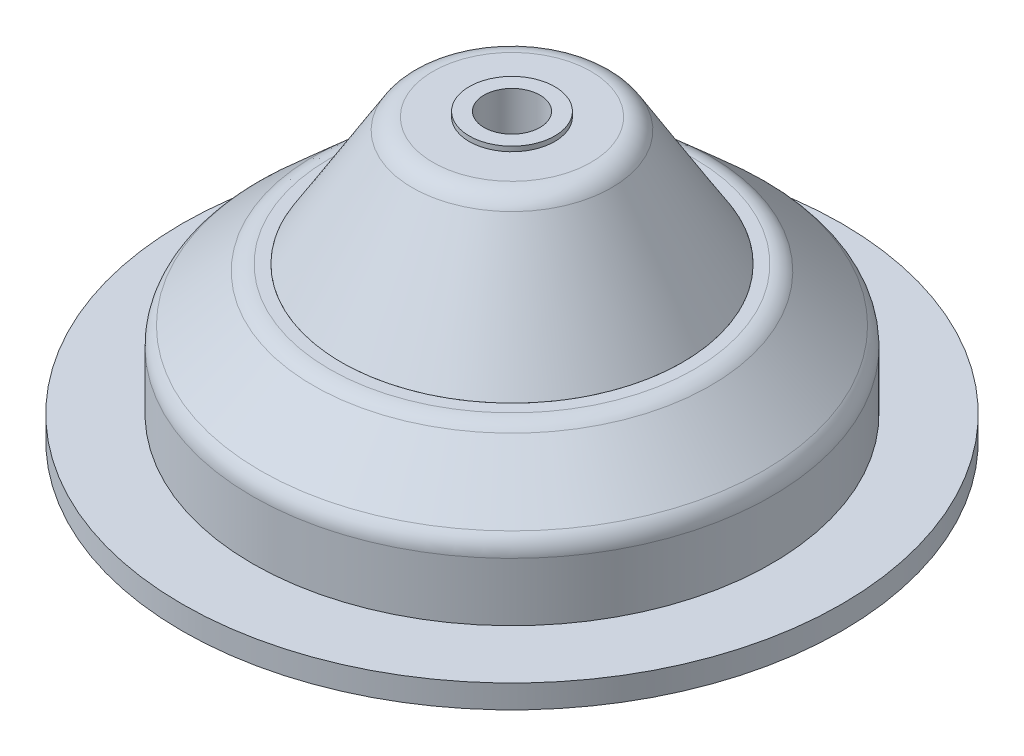
from build123d import *

# Parameters (mm, degrees)
SKETCH2_R           = 4.47675
SKETCH2_R_2         = 2.9337
BOSS_EXTRUDE1_DEPTH = 0.508
SKETCH3_R           = 6.99135
SKETCH3_R_2         = 2.9337
BOSS_EXTRUDE2_DEPTH = 8.0899
SKETCH4_R           = 6.0452
SKETCH4_R_2         = 2.9337
BOSS_EXTRUDE3_DEPTH = 1.016
BOSS_EXTRUDE4_DEPTH = 7.62


with BuildPart() as part:
    # Sketch1 → Revolve1 (revolve)
    with BuildSketch(Plane.XY):
        with BuildLine():
            Line((27.17165, 0), (34.5186, 0))
            Line((34.5186, 0), (34.5186, 2.4384))
            Line((34.5186, 2.4384), (27.17165, 2.4384))
            Line((27.17165, 2.4384), (27.17165, 8.540823407))
            ThreePointArc((27.17165, 8.540823407), (26.950119612, 9.578271554), (26.324170742, 10.434754118))
            Line((26.324170742, 10.434754118), (20.788951535, 15.381330711))
            ThreePointArc((20.788951535, 15.381330711), (20.002249757, 15.860392204), (19.096430792, 16.0274))
            Line((19.096430792, 16.0274), (17.84985, 16.0274))
            Line((17.84985, 16.0274), (24.9555, 9.6774))
            Line((24.9555, 9.6774), (24.9555, 0))
            Line((24.9555, 0), (27.17165, 0))
        make_face()
    revolve(axis=Axis((0, 0, 0), (0, 1, 0)))


with BuildPart() as body_2:
    # Sketch1_3 → Revolve2 (revolve)
    with BuildSketch(Plane.XY):
        with BuildLine():
            Line((2.9337, 16.0274), (17.84985, 16.0274))
            Line((17.84985, 16.0274), (10.433708778, 28.148063183))
            ThreePointArc((10.433708778, 28.148063183), (9.508951147, 29.038114838), (8.26709457, 29.3624))
            Line((8.26709457, 29.3624), (2.9337, 29.3624))
            Line((2.9337, 29.3624), (2.9337, 16.0274))
        make_face()
    revolve(axis=Axis((0, 0, 0), (0, 1, 0)))

    # Sketch2 → Boss-Extrude1 (add)
    with BuildSketch(Plane(origin=(0, 29.3624, 0), x_dir=(1, 0, 0), z_dir=(0, 1, 0))):
        Circle(SKETCH2_R)
        Circle(SKETCH2_R_2, mode=Mode.SUBTRACT)
    extrude(amount=BOSS_EXTRUDE1_DEPTH)

    # Sketch3 → Boss-Extrude2 (add)
    with BuildSketch(Plane.XZ.offset(-16.0274)):
        Circle(SKETCH3_R)
        Circle(SKETCH3_R_2, mode=Mode.SUBTRACT)
    extrude(amount=BOSS_EXTRUDE2_DEPTH)

    # Sketch4 → Boss-Extrude3 (add)
    with BuildSketch(Plane.XZ.offset(-7.9375)):
        Circle(SKETCH4_R)
        Circle(SKETCH4_R_2, mode=Mode.SUBTRACT)
    extrude(amount=BOSS_EXTRUDE3_DEPTH)

    # Sketch5 → Boss-Extrude4 (add)
    with BuildSketch(Plane.XZ.offset(-16.0274)):
        with BuildLine():
            ThreePointArc((-6.379230805, 2.860837142), (-6.034045723, 3.531184933), (-5.618677723, 4.160460968))
            Line((-5.618677723, 4.160460968), (-14.765958792, 10.029137848))
            ThreePointArc((-14.765958792, 10.029137848), (-15.510246483, 8.834557095), (-16.158099934, 7.585047892))
            Line((-16.158099934, 7.585047892), (-6.379230805, 2.860837142))
        make_face()
        with BuildLine():
            ThreePointArc((-5.667173044, -4.094157363), (-6.075118719, -3.460044417), (-6.412403751, -2.78568716))
            Line((-6.412403751, -2.78568716), (-16.068467551, -7.773126501))
            ThreePointArc((-16.068467551, -7.773126501), (-15.406074117, -9.014988925), (-14.647894131, -10.200801074))
            Line((-14.647894131, -10.200801074), (-5.667173044, -4.094157363))
        make_face()
        with BuildLine():
            Line((16.158099934, -7.585047892), (6.379230805, -2.860837142))
            ThreePointArc((6.379230805, -2.860837142), (6.034045723, -3.531184933), (5.618677723, -4.160460968))
            Line((5.618677723, -4.160460968), (14.765958792, -10.029137848))
            ThreePointArc((14.765958792, -10.029137848), (15.510246483, -8.834557095), (16.158099934, -7.585047892))
        make_face()
        with BuildLine():
            Line((14.647894131, 10.200801074), (5.667173044, 4.094157363))
            ThreePointArc((5.667173044, 4.094157363), (6.075118719, 3.460044417), (6.412403751, 2.78568716))
            Line((6.412403751, 2.78568716), (16.068467551, 7.773126501))
            ThreePointArc((16.068467551, 7.773126501), (15.406074117, 9.014988925), (14.647894131, 10.200801074))
        make_face()
        with BuildLine():
            ThreePointArc((0.712057762, -6.954994505), (-0.041072996, -6.991229351), (-0.793726028, -6.946148128))
            Line((-0.793726028, -6.946148128), (-1.302508759, -17.802264349))
            ThreePointArc((-1.302508759, -17.802264349), (0.104172366, -17.849546021), (1.510205804, -17.785848966))
            Line((1.510205804, -17.785848966), (0.712057762, -6.954994505))
        make_face()
        with BuildLine():
            Line((0.793726028, 6.946148128), (1.302508759, 17.802264349))
            ThreePointArc((1.302508759, 17.802264349), (-0.104172366, 17.849546021), (-1.510205804, 17.785848966))
            Line((-1.510205804, 17.785848966), (-0.712057762, 6.954994505))
            ThreePointArc((-0.712057762, 6.954994505), (0.041072996, 6.991229351), (0.793726028, 6.946148128))
        make_face()
    extrude(amount=BOSS_EXTRUDE4_DEPTH)


solid = Compound([part.part, body_2.part])
